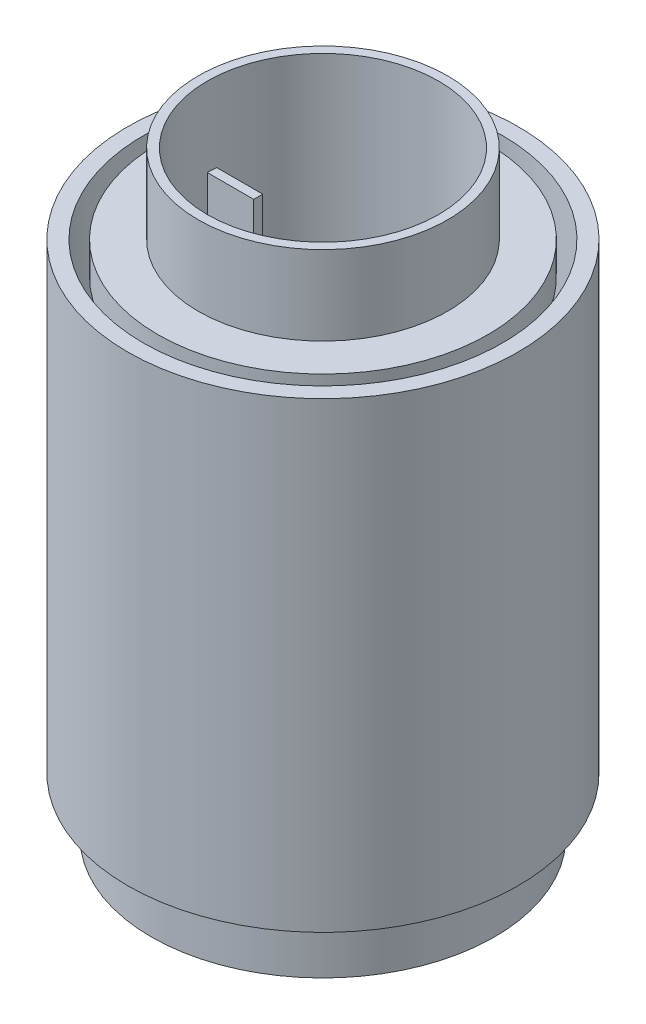
from build123d import *

# Parameters (mm, degrees)
CROQUIS1_R                = 25
CROQUIS1_R_2              = 17.677564449
SALIENTE_EXTRUIR1_DEPTH   = 5
CROQUIS3_R                = 17.644324771
CROQUIS3_R_2              = 17.517960831
SALIENTE_EXTRUIR3_DEPTH   = 70
CROQUIS6_R                = 26
CROQUIS6_R_2              = 17.517960831
SALIENTE_EXTRUIR5_DEPTH   = 8.5
SALIENTE_EXTRUIR6_DEPTH   = 70
SALIENTE_EXTRUIR6_2_DEPTH = 70
CROQUIS8_R                = 19.027539715
CROQUIS8_R_2              = 17.517960831
SALIENTE_EXTRUIR7_DEPTH   = 9
CROQUIS10_R               = 18.888693874
CROQUIS10_R_2             = 17.517960831
SALIENTE_EXTRUIR8_DEPTH   = 12
CROQUIS11_R               = 29.566795097
CROQUIS11_R_2             = 27.203212772
SALIENTE_EXTRUIR9_DEPTH   = 70


with BuildPart() as part:
    # Croquis1 → Saliente-Extruir1 (new body)
    with BuildSketch(Plane(origin=(0, 0, 0), x_dir=(1, 0, 0), z_dir=(0, 1, 0))):
        Circle(CROQUIS1_R)
        Circle(CROQUIS1_R_2, mode=Mode.SUBTRACT)
    extrude(amount=SALIENTE_EXTRUIR1_DEPTH)



with BuildPart() as body_2:
    # Croquis3 → Saliente-Extruir3 (new body)
    with BuildSketch(Plane(origin=(0, 5, 0), x_dir=(1, 0, 0), z_dir=(0, 1, 0))):
        Circle(CROQUIS3_R)
        Circle(CROQUIS3_R_2, mode=Mode.SUBTRACT)
    extrude(amount=-SALIENTE_EXTRUIR3_DEPTH)

    # Croquis6 → Saliente-Extruir5 (add)
    with BuildSketch(Plane(origin=(0, -65, 0), x_dir=(1, 0, 0), z_dir=(0, 1, 0))):
        Circle(CROQUIS6_R)
        Circle(CROQUIS6_R_2, mode=Mode.SUBTRACT)
    extrude(amount=-SALIENTE_EXTRUIR5_DEPTH)

    # Croquis8 → Saliente-Extruir7 (add)
    with BuildSketch(Plane(origin=(0, -65, 0), x_dir=(1, 0, 0), z_dir=(0, 1, 0))):
        Circle(CROQUIS8_R)
        Circle(CROQUIS8_R_2, mode=Mode.SUBTRACT)
    extrude(amount=-SALIENTE_EXTRUIR7_DEPTH)


with BuildPart() as body_3:
    # Croquis7 → Saliente-Extruir6 (new body, through all)
    with BuildSketch(Plane(origin=(0, -65, 0), x_dir=(1, 0, 0), z_dir=(0, 1, 0))):
        Polygon((17.465057261, 1.360414107), (10.484081817, 1.360414107), (10.484081817, 0), (17.517960831, 0), align=None)
    extrude(amount=SALIENTE_EXTRUIR6_DEPTH)


with BuildPart() as body_4:
    # Croquis7 → Saliente-Extruir6 2 (new body, through all)
    with BuildSketch(Plane(origin=(0, -65, 0), x_dir=(1, 0, 0), z_dir=(0, 1, 0))):
        Polygon((-17.517960831, 0), (-10.484081817, 0), (-10.484081817, 1.360414107), (-17.465057261, 1.360414107), align=None)
    extrude(amount=SALIENTE_EXTRUIR6_2_DEPTH)


with BuildPart() as part_1:
    add(part.part)

    add(body_2.part)  # Saliente-Extruir8 merges body 2
    # Croquis10 → Saliente-Extruir8 (add)
    with BuildSketch(Plane(origin=(0, 5, 0), x_dir=(1, 0, 0), z_dir=(0, 1, 0))):
        Circle(CROQUIS10_R)
        Circle(CROQUIS10_R_2, mode=Mode.SUBTRACT)
    extrude(amount=SALIENTE_EXTRUIR8_DEPTH)


with BuildPart() as body_4_2:
    # Croquis11 → Saliente-Extruir9 (new body)
    with BuildSketch(Plane(origin=(0, -65, 0), x_dir=(1, 0, 0), z_dir=(0, 1, 0))):
        Circle(CROQUIS11_R)
        Circle(CROQUIS11_R_2, mode=Mode.SUBTRACT)
    extrude(amount=SALIENTE_EXTRUIR9_DEPTH)


solid = Compound([body_3.part, body_4.part, part_1.part, body_4_2.part])
